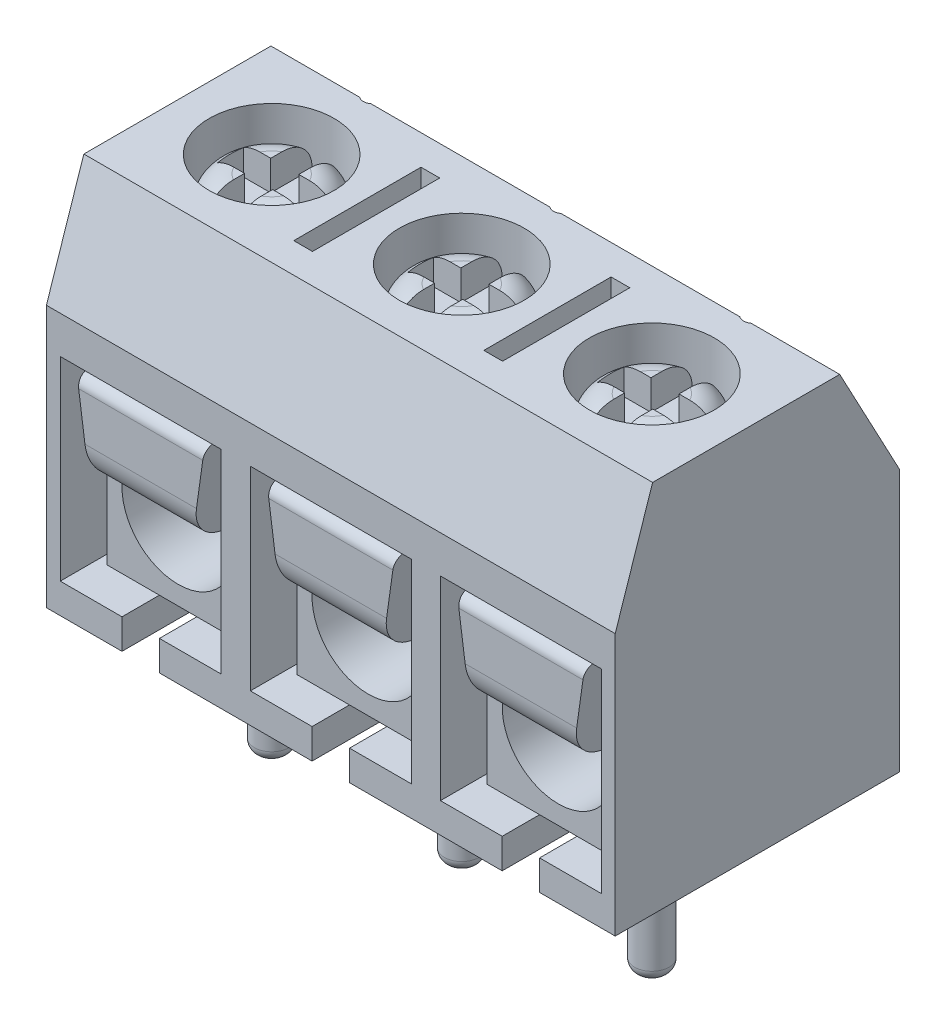
from build123d import *

# Parameters (mm, degrees)
BOSS_EXTRUDE1_DEPTH = 7.6
SKETCH3_R           = 1.67
CUT_EXTRUDE1_DEPTH  = 1.75
SKETCH4_R           = 0.25
SKETCH4_W           = 0.5
SKETCH4_H           = 3.4
CUT_EXTRUDE2_DEPTH  = 2
SKETCH5_W           = 4.3
SKETCH5_H           = 5.2
CUT_EXTRUDE3_DEPTH  = 6
CUT_EXTRUDE4_DEPTH  = 0.8
SKETCH9_R           = 1.5
BOSS_EXTRUDE5_DEPTH = 1.3
FILLET1_R           = 0.75
SKETCH10_W          = 0.75
SKETCH10_H          = 3.1
CUT_EXTRUDE5_DEPTH  = 0.8
SKETCH11_W          = 2.2
SKETCH11_H          = 0.7
CUT_EXTRUDE6_DEPTH  = 0.8
SKETCH7_W           = 14.46
SKETCH7_H           = 5.2
BOSS_EXTRUDE3_DEPTH = 0.5
SKETCH8_W           = 3.8
SKETCH8_H           = 5
SKETCH8_R           = 1.5
BOSS_EXTRUDE4_DEPTH = 4.5
FILLET2_R           = 0.2
BOSS_EXTRUDE6_DEPTH = 5.5
FILLET3_R           = 1
FILLET4_R           = 0.3
SKETCH13_R          = 0.46
BOSS_EXTRUDE7_DEPTH = 4.6
FILLET5_R           = 0.3


with BuildPart() as part:
    # Sketch1 → Boss-Extrude1 (new body, symmetric)
    with BuildSketch(Plane(origin=(0, 0, 0), x_dir=(0, 0, -1), z_dir=(1, 0, 0))):
        Polygon((-3.5, 0), (4.1, 0), (4.1, 7), (2.5, 10), (-2.5, 10), (-3.5, 7), align=None)
    extrude(amount=BOSS_EXTRUDE1_DEPTH, both=True)

    # Sketch3 → Cut-Extrude1 (cut)
    with BuildSketch(Plane(origin=(0, 10, 0), x_dir=(1, 0, 0), z_dir=(0, 1, 0))):
        Circle(SKETCH3_R)
        with Locations((-5.08, 0)):
            Circle(SKETCH3_R)
        with Locations((5.08, 0)):
            Circle(SKETCH3_R)
    extrude(amount=-CUT_EXTRUDE1_DEPTH, mode=Mode.SUBTRACT)

    # Sketch4 → Cut-Extrude2 (cut)
    with BuildSketch(Plane(origin=(0, 10, 0), x_dir=(1, 0, 0), z_dir=(0, 1, 0))):
        with Locations((0, 2.7)):
            Circle(SKETCH4_R)
        with Locations((5.08, 2.7)):
            Circle(SKETCH4_R)
        with Locations((-5.08, 2.7)):
            Circle(SKETCH4_R)
        with Locations((-2.54, 0)):
            Rectangle(SKETCH4_W, SKETCH4_H)
        with Locations((2.54, 0)):
            Rectangle(SKETCH4_W, SKETCH4_H)
    extrude(amount=-CUT_EXTRUDE2_DEPTH, mode=Mode.SUBTRACT)

    # Sketch5 → Cut-Extrude3 (cut)
    with BuildSketch(Plane.XY.offset(3.5)):
        with Locations((0, 3.4)):
            Rectangle(SKETCH5_W, SKETCH5_H)
        with Locations((-5.08, 3.4)):
            Rectangle(SKETCH5_W, SKETCH5_H)
        with Locations((5.08, 3.4)):
            Rectangle(SKETCH5_W, SKETCH5_H)
    extrude(amount=-CUT_EXTRUDE3_DEPTH, mode=Mode.SUBTRACT)

    # Sketch6 → Cut-Extrude4 (cut)
    with BuildSketch(Plane.XZ):
        with BuildLine():
            Line((-0.5, 0), (-0.5, 3.5))
            ThreePointArc((-0.5, 3.5), (0, 4), (0.5, 3.5))
            Line((0.5, 3.5), (0.5, 0))
            ThreePointArc((0.5, 0), (0, -0.5), (-0.5, 0))
        make_face()
        with BuildLine():
            Line((-5.58, 0), (-5.58, 3.5))
            ThreePointArc((-5.58, 3.5), (-5.08, 4), (-4.58, 3.5))
            Line((-4.58, 3.5), (-4.58, 0))
            ThreePointArc((-4.58, 0), (-5.08, -0.5), (-5.58, 0))
        make_face()
        with BuildLine():
            Line((4.58, 0), (4.58, 3.5))
            ThreePointArc((4.58, 3.5), (5.08, 4), (5.58, 3.5))
            Line((5.58, 3.5), (5.58, 0))
            ThreePointArc((5.58, 0), (5.08, -0.5), (4.58, 0))
        make_face()
    extrude(amount=-CUT_EXTRUDE4_DEPTH, mode=Mode.SUBTRACT)

    # Sketch9 → Boss-Extrude5 (add)
    with BuildSketch(Plane(origin=(0, 8.25, 0), x_dir=(1, 0, 0), z_dir=(0, 1, 0))):
        Circle(SKETCH9_R)
        with Locations((5.08, 0)):
            Circle(SKETCH9_R)
        with Locations((-5.08, 0)):
            Circle(SKETCH9_R)
    extrude(amount=BOSS_EXTRUDE5_DEPTH)

    # Fillet1
    fillet1_edges = [part.edges().sort_by_distance(p)[0] for p in [
        (-1.5, 9.55, 0),
        (3.58, 9.55, 0),
        (-6.58, 9.55, 0),
    ]]
    fillet(fillet1_edges, radius=FILLET1_R)

    # Sketch10 → Cut-Extrude5 (cut)
    with BuildSketch(Plane(origin=(0, 9.55, 0), x_dir=(1, 0, 0), z_dir=(0, 1, 0))):
        Rectangle(SKETCH10_W, SKETCH10_H)
        with Locations((-5.08, 0)):
            Rectangle(SKETCH10_W, SKETCH10_H)
        with Locations((5.08, 0)):
            Rectangle(SKETCH10_W, SKETCH10_H)
    extrude(amount=-CUT_EXTRUDE5_DEPTH, mode=Mode.SUBTRACT)

    # Sketch11 → Cut-Extrude6 (cut)
    with BuildSketch(Plane(origin=(0, 9.55, 0), x_dir=(1, 0, 0), z_dir=(0, 1, 0))):
        Rectangle(SKETCH11_W, SKETCH11_H)
        with Locations((-5.08, 0)):
            Rectangle(SKETCH11_W, SKETCH11_H)
        with Locations((5.08, 0)):
            Rectangle(SKETCH11_W, SKETCH11_H)
    extrude(amount=-CUT_EXTRUDE6_DEPTH, mode=Mode.SUBTRACT)


with BuildPart() as body_2:
    # Sketch7 → Boss-Extrude3 (new body)
    with BuildSketch(Plane.XY.offset(-2.5)):
        with Locations((0, 3.4)):
            Rectangle(SKETCH7_W, SKETCH7_H)
    extrude(amount=BOSS_EXTRUDE3_DEPTH)

    # Sketch8 → Boss-Extrude4 (add)
    with BuildSketch(Plane.XY.offset(-2)):
        with Locations((-5.08, 3.3)):
            Rectangle(SKETCH8_W, SKETCH8_H)
        with Locations((-5.08, 2.8)):
            Circle(SKETCH8_R, mode=Mode.SUBTRACT)
        with Locations((0, 3.3)):
            Rectangle(SKETCH8_W, SKETCH8_H)
        with Locations((0, 2.8)):
            Circle(SKETCH8_R, mode=Mode.SUBTRACT)
        with Locations((5.08, 3.3)):
            Rectangle(SKETCH8_W, SKETCH8_H)
        with Locations((5.08, 2.8)):
            Circle(SKETCH8_R, mode=Mode.SUBTRACT)
    extrude(amount=BOSS_EXTRUDE4_DEPTH)

    # Fillet2
    fillet2_edges = [body_2.edges().sort_by_distance(p)[0] for p in [
        (-6.98, 5.8, 0.25),
        (-3.18, 5.8, 0.25),
        (-1.9, 5.8, 0.25),
        (1.9, 5.8, 0.25),
        (3.18, 5.8, 0.25),
        (6.98, 5.8, 0.25),
    ]]
    fillet(fillet2_edges, radius=FILLET2_R)

    # Sketch12 → Boss-Extrude6 (add)
    with BuildSketch(Plane.XY.offset(3.5)):
        Polygon((1.35, 3.3), (-1.35, 3.3), (-1.7, 5.8), (1.7, 5.8), align=None)
        Polygon((-6.78, 5.8), (-3.38, 5.8), (-3.73, 3.3), (-6.43, 3.3), align=None)
        Polygon((3.38, 5.8), (6.78, 5.8), (6.43, 3.3), (3.73, 3.3), align=None)
    extrude(amount=-BOSS_EXTRUDE6_DEPTH)

    # Fillet3
    fillet3_edges = [body_2.edges().sort_by_distance(p)[0] for p in [
        (0, 3.3, 3.5),
        (-5.08, 3.3, 3.5),
        (5.08, 3.3, 3.5),
    ]]
    fillet(fillet3_edges, radius=FILLET3_R)

    # Fillet4
    fillet4_edges = [body_2.edges().sort_by_distance(p)[0] for p in [
        (-5.08, 5.8, 3.5),
        (5.08, 5.8, 3.5),
        (0, 5.8, 3.5),
    ]]
    fillet(fillet4_edges, radius=FILLET4_R)

    # Sketch13 → Boss-Extrude7 (add)
    with BuildSketch(Plane.XZ.offset(-0.8)):
        Circle(SKETCH13_R)
        with Locations((5.08, 0)):
            Circle(SKETCH13_R)
        with Locations((-5.08, 0)):
            Circle(SKETCH13_R)
    extrude(amount=BOSS_EXTRUDE7_DEPTH)

    # Fillet5
    fillet5_edges = [body_2.edges().sort_by_distance(p)[0] for p in [
        (-0.46, -3.8, 0),
        (4.62, -3.8, 0),
        (-5.54, -3.8, 0),
    ]]
    fillet(fillet5_edges, radius=FILLET5_R)


solid = Compound([part.part, body_2.part])
